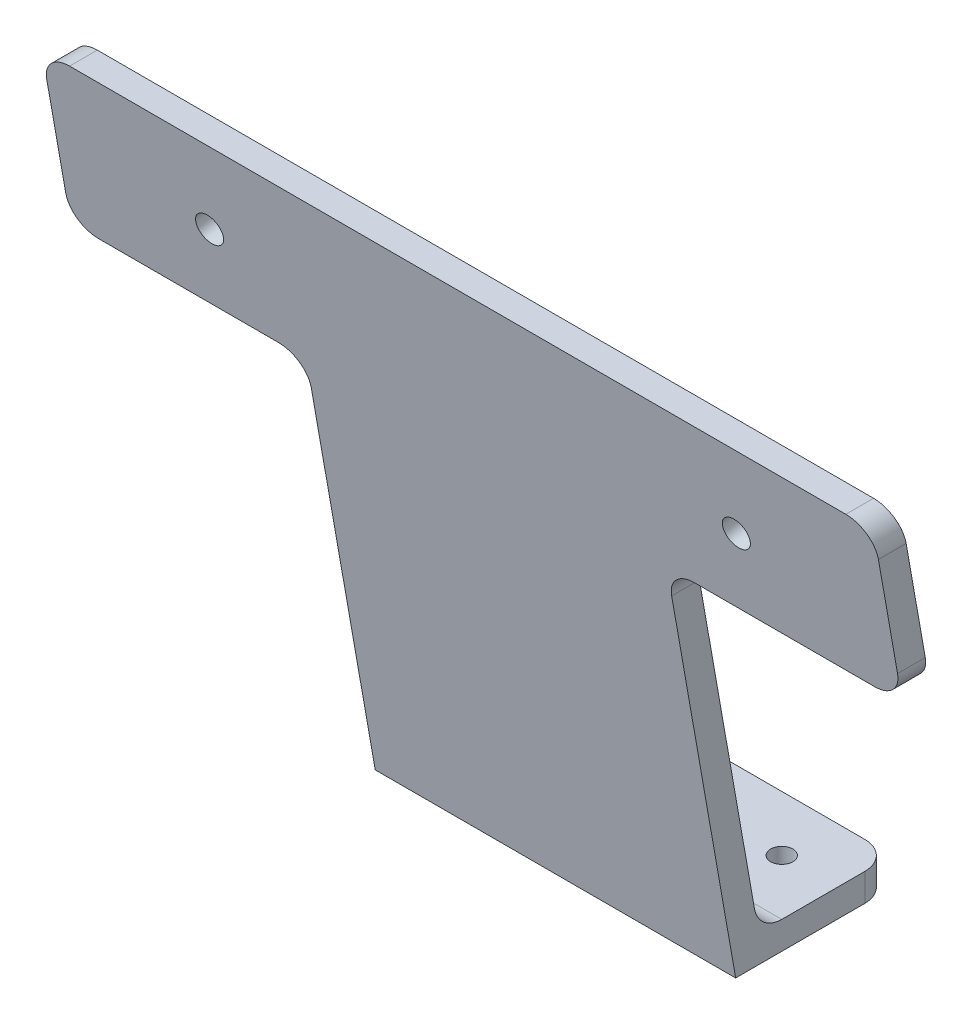
from build123d import *
from build123d.topology import SkipClean

# Parameters (mm, degrees)
BOSS_EXTRUDE1_DEPTH      = 65
SKETCH2_W                = 42.5
SKETCH2_H                = 30
BOSS_EXTRUDE2_DEPTH      = 5.000000239
FILLET1_R                = 5
CUT_EXTRUDE1_REACH       = 148.226
SKETCH3_R                = 2
SKETCH5_R                = 2.5
CUT_EXTRUDE2_DEPTH       = 149.107763403
BOSS_EXTRUDE3_DEPTH      = 4
BOSS_EXTRUDE3_DEPTH_BACK = 4


with BuildPart() as part:
    # Sketch1 → Boss-Extrude1 (new body)
    with BuildSketch(Plane(origin=(0, 0, 0), x_dir=(0, 0, -1), z_dir=(1, 0, 0))):
        Polygon((-17.632698071, 100), (0, 0), (28.3, 0), (28.3, 5), (4.118365096, 5), (-12.632698071, 100), align=None)
    extrude(amount=BOSS_EXTRUDE1_DEPTH)

    # Sketch2 → Boss-Extrude2 (add, along a direction that is not the sketch's normal)
    with SkipClean():  # the faces are left unmerged after this step: merging them gives an invalid solid
        with BuildSketch(Plane(origin=(0, 0, 0), x_dir=(1, 0, 0), z_dir=(0, -0.1736481776669274, 0.9848077530122086))):
            with Locations((-21.25, 86.542661189)):
                Rectangle(SKETCH2_W, SKETCH2_H)
            with Locations((86.25, 86.542661189)):
                Rectangle(SKETCH2_W, SKETCH2_H)
        extrude(amount=-BOSS_EXTRUDE2_DEPTH, dir=(0, 0, 1))

    # Fillet1
    fillet1_edges = [part.edges().sort_by_distance(p)[0] for p in [
        (32.5, 5, -4.118365096),
        (65, 2.5, -28.3),
        (0, 70.45576741, 9.923252622),
        (107.5, 70.45576741, 9.923252622),
        (65, 70.45576741, 9.923252622),
        (-42.5, 70.45576741, 9.923252622),
        (-42.5, 100, 15.132697952),
        (107.5, 100, 15.132697952),
        (0, 2.5, -28.3),
    ]]
    fillet(fillet1_edges, radius=FILLET1_R)

    # Sketch3 → Cut-Extrude1 (cut, up to next)
    with BuildSketch(Plane(origin=(0, 5, 0), x_dir=(1, 0, 0), z_dir=(0, 1, 0)), mode=Mode.PRIVATE) as cut_extrude1_sk1:
        with Locations(Location((10, 18.313863252, 0), (0, 0, 270))):
            Circle(SKETCH3_R)
    cut_extrude1_tool1 = extrude(cut_extrude1_sk1.sketch, amount=-CUT_EXTRUDE1_REACH, mode=Mode.PRIVATE) & part.part
    # Sketch3 → Cut-Extrude1 (cut, up to next)
    with BuildSketch(Plane(origin=(0, 5, 0), x_dir=(1, 0, 0), z_dir=(0, 1, 0)), mode=Mode.PRIVATE) as cut_extrude1_sk2:
        with Locations(Location((55, 18.313863252, 0), (0, 0, 270))):
            Circle(SKETCH3_R)
    cut_extrude1_tool2 = extrude(cut_extrude1_sk2.sketch, amount=-CUT_EXTRUDE1_REACH, mode=Mode.PRIVATE) & part.part
    add(cut_extrude1_tool1.solids().sort_by_distance((10, 5, -18.313863))[0], mode=Mode.SUBTRACT)
    add(cut_extrude1_tool2.solids().sort_by_distance((55, 5, -18.313863))[0], mode=Mode.SUBTRACT)

    # Sketch5 → Cut-Extrude2 (cut, through all)
    with SkipClean():  # the faces are left unmerged after this step: merging them gives an invalid solid
        with BuildSketch(Plane(origin=(0, 0.855050358, -4.849231552), x_dir=(-1, 0, 0), z_dir=(0, 0.1736481776669273, -0.9848077530122086))):
            with Locations(Location((-80, 85.6744203, 0), (0, 0, 90))):
                Circle(SKETCH5_R)
            with Locations(Location((15, 85.6744203, 0), (0, 0, 90))):
                Circle(SKETCH5_R)
        extrude(amount=-CUT_EXTRUDE2_DEPTH, mode=Mode.SUBTRACT)

    # Sketch9 → Boss-Extrude3 (add, two sides)
    with SkipClean():  # the faces are left unmerged after this step: merging them gives an invalid solid
        with BuildSketch(Plane.ZY.offset(-32.5)) as boss_extrude3_sk:
            with BuildLine():
                Line((-25.100344966, 5), (-8.313863252, 5))
                ThreePointArc((-8.313863252, 5), (-5.099925204, 6.169777784), (-3.389824487, 9.131759112))
                Line((-3.389824487, 9.131759112), (7.130723416, 68.796751166))
                Line((7.130723416, 68.796751166), (-25.100344966, 5))
            make_face()
        extrude(amount=BOSS_EXTRUDE3_DEPTH)
        extrude(boss_extrude3_sk.sketch, amount=-BOSS_EXTRUDE3_DEPTH_BACK)


solid = part.part
